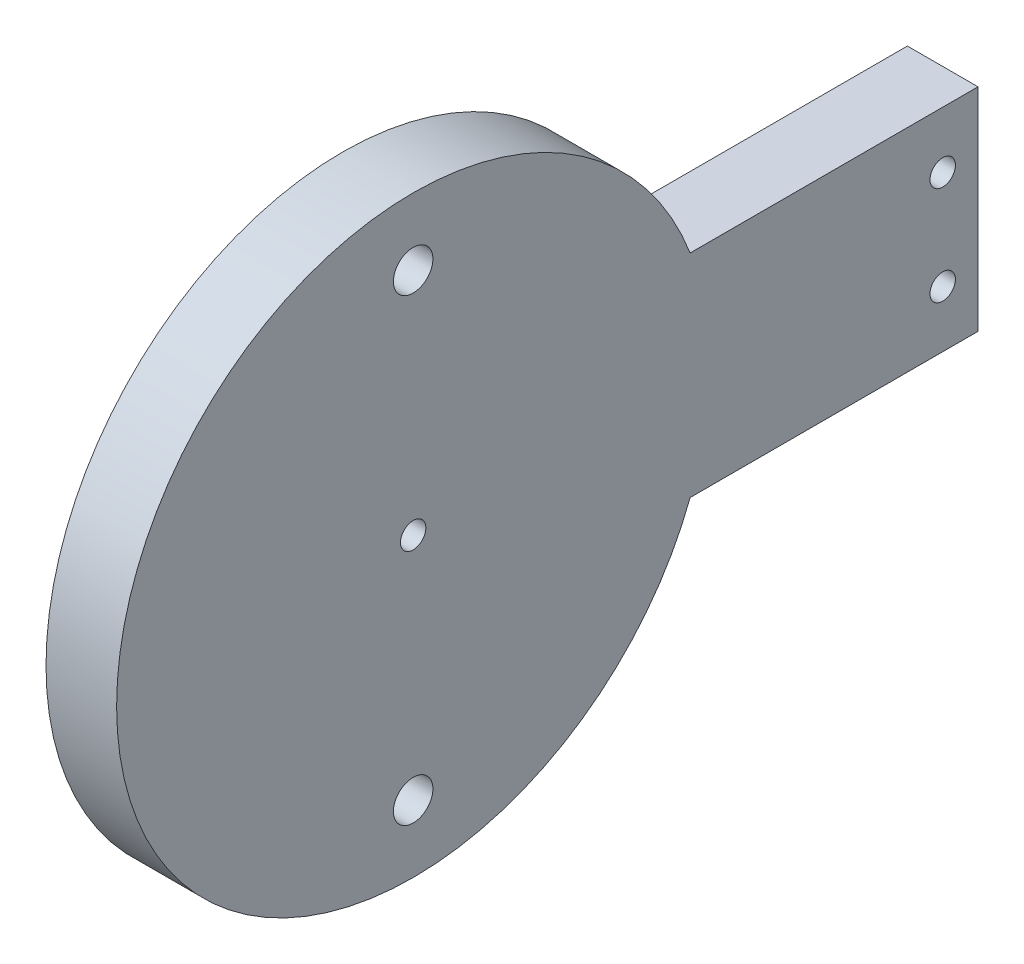
from build123d import *

# Parameters (mm, degrees)
EXTRUDE_1_DEPTH     = 5
SKETCH_8_R          = 0.9
SKETCH_8_R_2        = 1.4
CUT_EXTRUDE_3_DEPTH = 10


with BuildPart() as part:
    # 스케치1 → 보스-돌출1 (new body)
    with BuildSketch(Plane(origin=(-9, 0, 0), x_dir=(0, -1, 0), z_dir=(-1, 0, 0))):
        with BuildLine():
            Line((-21, -18.122865071), (-21, 2.262089683))
            ThreePointArc((-21, 2.262089683), (-13.5, 42.877134929), (-6, 2.262089683))
            Line((-6, 2.262089683), (-6, -18.122865071))
            Line((-6, -18.122865071), (-21, -18.122865071))
        make_face()
    extrude(amount=-EXTRUDE_1_DEPTH)

    # 스케치8 → 컷-돌출3 (cut)
    with BuildSketch(Plane.ZY.offset(9)):
        with Locations((21.877134929, 13.5)):
            Circle(SKETCH_8_R)
        with Locations((-15.622865071, 17)):
            Circle(SKETCH_8_R)
        with Locations((-15.622865071, 10)):
            Circle(SKETCH_8_R)
        with Locations((21.877134929, 29.75)):
            Circle(SKETCH_8_R_2)
        with Locations((21.877134929, -2.75)):
            Circle(SKETCH_8_R_2)
    extrude(amount=-CUT_EXTRUDE_3_DEPTH, mode=Mode.SUBTRACT)


solid = part.part
